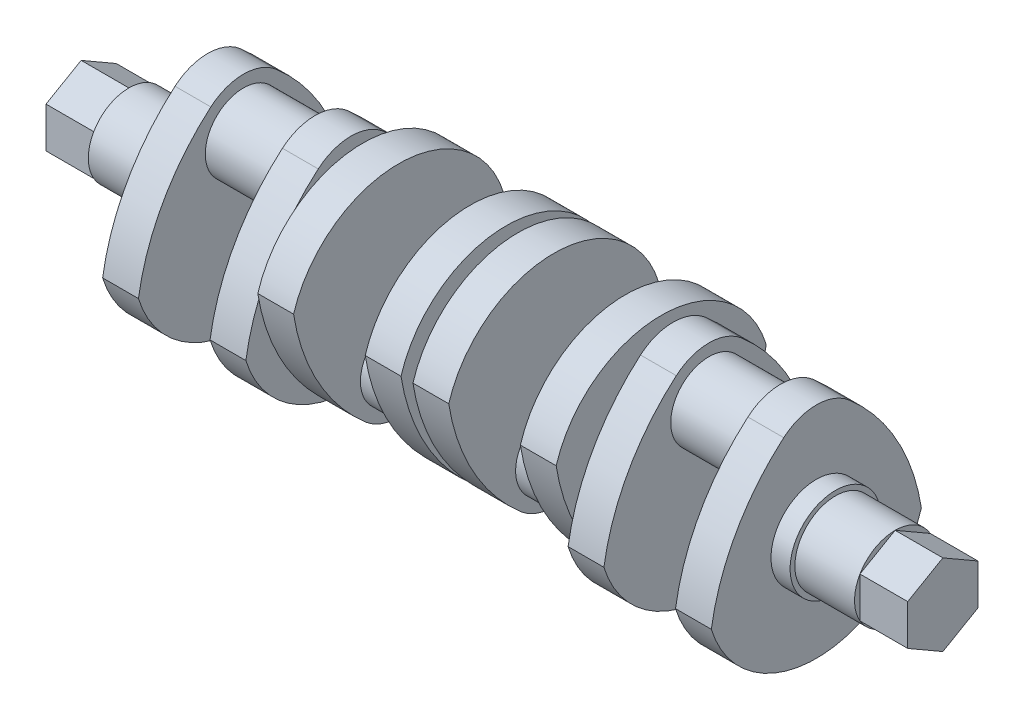
from build123d import *

# Parameters (mm, degrees)
SKETCH1_R            = 17
BOSS_EXTRUDE1_DEPTH  = 25
SKETCH1_3_R          = 19
BOSS_EXTRUDE2_DEPTH  = 8
BOSS_EXTRUDE3_DEPTH  = 15
SKETCH5_R            = 16
BOSS_EXTRUDE4_DEPTH  = 15
BOSS_EXTRUDE5_START  = 5
SKETCH6_R            = 17
BOSS_EXTRUDE5_DEPTH  = 5
BOSS_EXTRUDE6_DEPTH  = 15
SKETCH8_R            = 16
BOSS_EXTRUDE7_DEPTH  = 30
BOSS_EXTRUDE8_DEPTH  = 15
BOSS_EXTRUDE9_START  = 2.5
SKETCH10_R           = 17
BOSS_EXTRUDE9_DEPTH  = 2.5
BOSS_EXTRUDE10_DEPTH = 20
BOSS_EXTRUDE11_DEPTH = 20


with BuildPart() as part:
    # Sketch1 → Boss-Extrude1 (new body)
    with BuildSketch(Plane(origin=(0, 0, 0), x_dir=(0, 0, -1), z_dir=(1, 0, 0))):
        Circle(SKETCH1_R)
    extrude(amount=BOSS_EXTRUDE1_DEPTH)

    # Sketch1_3 → Boss-Extrude2 (add)
    with BuildSketch(Plane(origin=(0, 0, 0), x_dir=(0, 0, -1), z_dir=(1, 0, 0))):
        Circle(SKETCH1_3_R)
    extrude(amount=-BOSS_EXTRUDE2_DEPTH)

    # Sketch4 → Boss-Extrude3 (add)
    with BuildSketch(Plane.ZY.offset(8)):
        with BuildLine():
            ThreePointArc((-13.668094758, 40.943123461), (0, 46), (13.668094758, 40.943123461))
            ThreePointArc((13.668094758, 40.943123461), (33.683444249, 16.469257624), (44, -13.416407865))
            ThreePointArc((44, -13.416407865), (0, -46), (-44, -13.416407865))
            ThreePointArc((-44, -13.416407865), (-33.683444249, 16.469257624), (-13.668094758, 40.943123461))
        make_face()
    boss_extrude3 = extrude(amount=BOSS_EXTRUDE3_DEPTH)

    # Sketch5 → Boss-Extrude4 (add)
    with BuildSketch(Plane.ZY.offset(23)):
        with Locations((0, 25)):
            Circle(SKETCH5_R)
    boss_extrude4 = extrude(amount=BOSS_EXTRUDE4_DEPTH)

    # Mirror1: Boss-Extrude3, Boss-Extrude4 across plane
    add(boss_extrude3.mirror(Plane(origin=(-38, 25, 0), x_dir=(0, 0, 1), z_dir=(-1, 0, 0))))
    add(boss_extrude4.mirror(Plane(origin=(-38, 25, 0), x_dir=(0, 0, 1), z_dir=(-1, 0, 0))))

    # Sketch6 → Boss-Extrude5 (add)
    with BuildSketch(Plane.ZY.offset(68).offset(BOSS_EXTRUDE5_START)):
        Circle(SKETCH6_R)
    extrude(amount=-BOSS_EXTRUDE5_DEPTH)

    # Sketch7 → Boss-Extrude6 (add)
    with BuildSketch(Plane.ZY.offset(73)):
        with BuildLine():
            ThreePointArc((-13.668094758, -40.943123461), (0, -46), (13.668094758, -40.943123461))
            ThreePointArc((13.668094758, -40.943123461), (33.683444249, -16.469257624), (44, 13.416407865))
            ThreePointArc((44, 13.416407865), (0, 46), (-44, 13.416407865))
            ThreePointArc((-44, 13.416407865), (-33.683444249, -16.469257624), (-13.668094758, -40.943123461))
        make_face()
    extrude(amount=BOSS_EXTRUDE6_DEPTH)

    # Sketch8 → Boss-Extrude7 (add)
    with BuildSketch(Plane.ZY.offset(88)):
        with Locations((0, -25)):
            Circle(SKETCH8_R)
    extrude(amount=BOSS_EXTRUDE7_DEPTH)

    # Sketch9 → Boss-Extrude8 (add)
    with BuildSketch(Plane.ZY.offset(118)):
        with BuildLine():
            ThreePointArc((-13.668094758, -40.943123461), (0, -46), (13.668094758, -40.943123461))
            ThreePointArc((13.668094758, -40.943123461), (33.683444249, -16.469257624), (44, 13.416407865))
            ThreePointArc((44, 13.416407865), (0, 46), (-44, 13.416407865))
            ThreePointArc((-44, 13.416407865), (-33.683444249, -16.469257624), (-13.668094758, -40.943123461))
        make_face()
    extrude(amount=BOSS_EXTRUDE8_DEPTH)

    # Sketch10 → Boss-Extrude9 (add)
    with BuildSketch(Plane.ZY.offset(133).offset(BOSS_EXTRUDE9_START)):
        Circle(SKETCH10_R)
    extrude(amount=-BOSS_EXTRUDE9_DEPTH)

    # Mirror2: part across plane


with BuildPart() as part_1:
    add(part.part)
    add(part.part.mirror(Plane.ZY.offset(135.5)))

    # Sketch11 → Boss-Extrude10 (add)
    with BuildSketch(Plane(origin=(25, 0, 0), x_dir=(0, 0, -1), z_dir=(1, 0, 0))):
        Polygon((14.722431864, -8.5), (14.722431864, 8.5), (0, 17), (-14.722431864, 8.5), (-14.722431864, -8.5), (0, -17), align=None)
    extrude(amount=BOSS_EXTRUDE10_DEPTH)

    # Sketch12 → Boss-Extrude11 (add)
    with BuildSketch(Plane.ZY.offset(296)):
        Polygon((-14.722431864, 8.5), (-14.722431864, -8.5), (0, -17), (14.722431864, -8.5), (14.722431864, 8.5), (0, 17), align=None)
    extrude(amount=BOSS_EXTRUDE11_DEPTH)


solid = part_1.part
